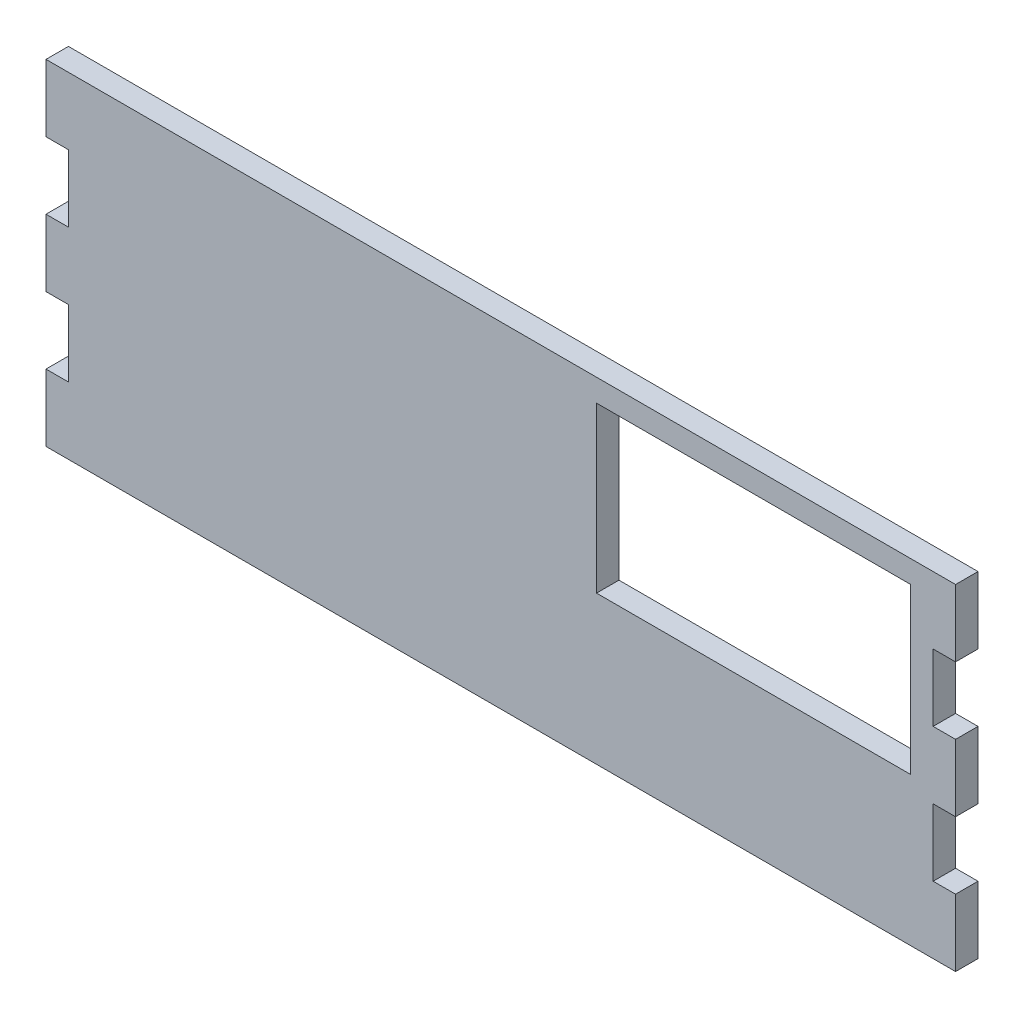
from build123d import *

# Parameters (mm, degrees)
SKETCH1_W           = 121.6
SKETCH1_H           = 44.82
BOSS_EXTRUDE1_DEPTH = 3
CUT_EXTRUDE1_REACH  = 5
SKETCH4_W           = 42
SKETCH4_H           = 22
SKETCH5_W           = 3
SKETCH5_H           = 8.964
CUT_EXTRUDE2_DEPTH  = 4


with BuildPart() as part:
    # Sketch1 → Boss-Extrude1 (new body)
    with BuildSketch(Plane.XY):
        with Locations((60.8, 22.41)):
            Rectangle(SKETCH1_W, SKETCH1_H)
    extrude(amount=BOSS_EXTRUDE1_DEPTH)

    # Sketch4 → Cut-Extrude1 (cut, up to next)
    with BuildSketch(Plane.XY.offset(3), mode=Mode.PRIVATE) as cut_extrude1_sk1:
        with Locations((94.6, 30.82)):
            Rectangle(SKETCH4_W, SKETCH4_H)
    cut_extrude1_tool1 = extrude(cut_extrude1_sk1.sketch, amount=-CUT_EXTRUDE1_REACH, mode=Mode.PRIVATE) & part.part
    add(cut_extrude1_tool1.solids().sort_by_distance((94.6, 30.82, 3))[0], mode=Mode.SUBTRACT)

    # Sketch5 → Cut-Extrude2 (cut, through all)
    with BuildSketch(Plane.XY.offset(3)):
        with Locations((1.5, 13.446)):
            Rectangle(SKETCH5_W, SKETCH5_H)
        with Locations((1.5, 31.374)):
            Rectangle(SKETCH5_W, SKETCH5_H)
        with Locations((120.1, 13.446)):
            Rectangle(SKETCH5_W, SKETCH5_H)
        with Locations((120.1, 31.374)):
            Rectangle(SKETCH5_W, SKETCH5_H)
    extrude(amount=-CUT_EXTRUDE2_DEPTH, mode=Mode.SUBTRACT)


solid = part.part
